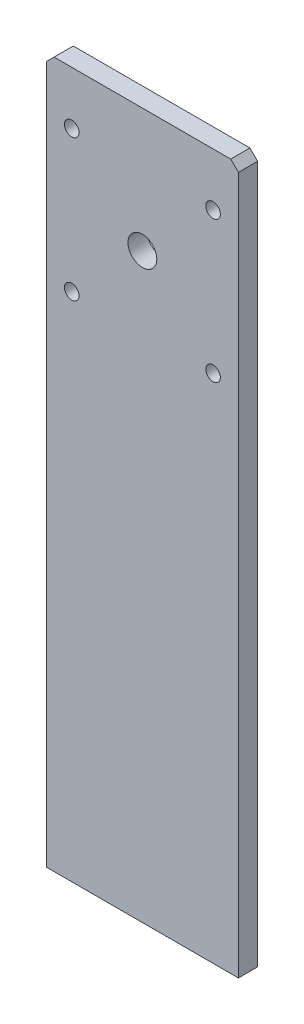
from build123d import *

# Parameters (mm, degrees)
SKETCH1_W           = 63.5
SKETCH1_H           = 233.2736
SKETCH1_R           = 2.413
SKETCH1_R_2         = 4.7625
BOSS_EXTRUDE1_DEPTH = 6.35
CHAMFER1_SIZE       = 2.54


with BuildPart() as part:
    # Sketch1 → Boss-Extrude1 (new body)
    with BuildSketch(Plane.XY):
        with Locations((31.75, 116.6368)):
            Rectangle(SKETCH1_W, SKETCH1_H)
        with Locations((8.382, 215.7476)):
            Circle(SKETCH1_R, mode=Mode.SUBTRACT)
        with Locations((55.118, 215.7476)):
            Circle(SKETCH1_R, mode=Mode.SUBTRACT)
        with Locations((8.382, 169.0116)):
            Circle(SKETCH1_R, mode=Mode.SUBTRACT)
        with Locations((55.118, 169.0116)):
            Circle(SKETCH1_R, mode=Mode.SUBTRACT)
        with Locations((31.75, 192.3796)):
            Circle(SKETCH1_R_2, mode=Mode.SUBTRACT)
    extrude(amount=BOSS_EXTRUDE1_DEPTH)

    # Chamfer1
    chamfer1_edges = [part.edges().sort_by_distance(p)[0] for p in [
        (0, 233.2736, 3.175),
        (63.5, 233.2736, 3.175),
    ]]
    chamfer(chamfer1_edges, length=CHAMFER1_SIZE)


solid = part.part
